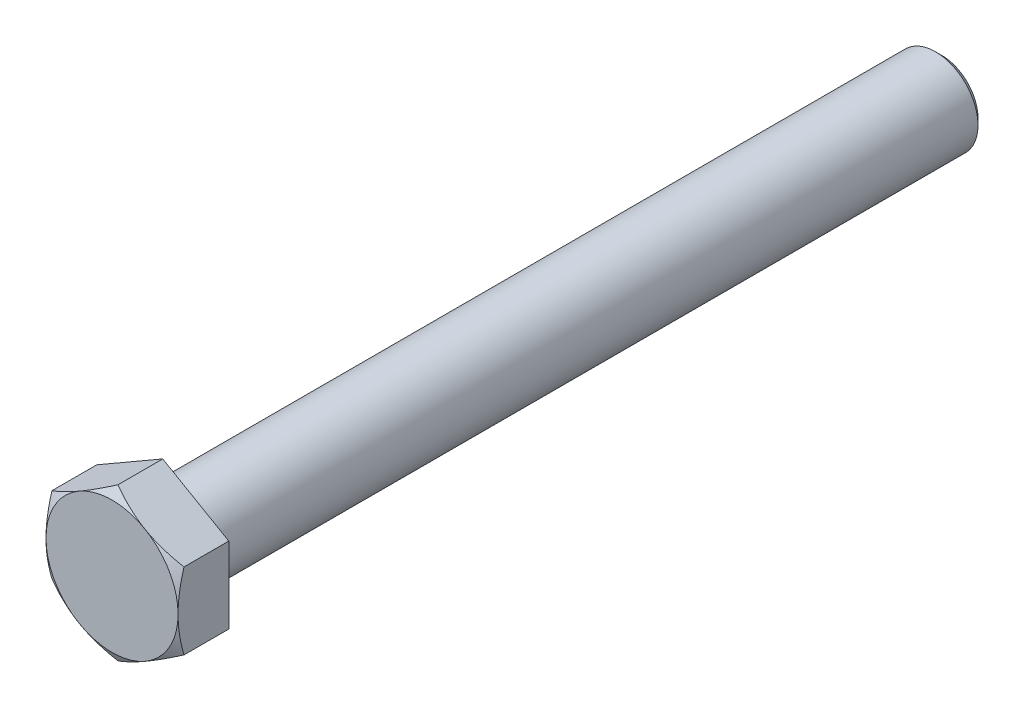
from build123d import *

# Parameters (mm, degrees)
BOSS_EXTRUDE1_DEPTH = 7.32


with BuildPart() as part:
    # Sketch1 → Boss-Extrude1 (new body)
    with BuildSketch(Plane.XY):
        Polygon((0, 10.779129526), (-9.335, 5.389564763), (-9.335, -5.389564763), (0, -10.779129526), (9.335, -5.389564763), (9.335, 5.389564763), align=None)
    extrude(amount=BOSS_EXTRUDE1_DEPTH)

    # Sketch2 → Revolve1 (revolve)
    with BuildSketch(Plane(origin=(0, 0, 0), x_dir=(0, 0, -1), z_dir=(1, 0, 0))):
        with BuildLine():
            Line((0, 0), (0, 6.6))
            ThreePointArc((0, 6.6), (0.175735931, 6.175735931), (0.6, 6))
            Line((0.6, 6), (109.1, 6))
            Line((109.1, 6), (110, 5.1))
            Line((110, 5.1), (110, 0))
            Line((110, 0), (0, 0))
        make_face()
    revolve(axis=Axis((0, 0, 0), (0, 0, -1)))

    # Sketch3 → Cut-Revolve1 (revolve, cut)
    with BuildSketch(Plane(origin=(0, 0, 0), x_dir=(0, 0, -1), z_dir=(1, 0, 0))):
        Polygon((-7.32, 10.779129526), (-6.48623143, 10.779129526), (-7.32, 9.335), align=None)
        Polygon((-0.15, 10.779129526), (-0.15, 8.78660254), (0, 8.7), (0, 10.779129526), align=None)
    revolve(axis=Axis((0, 0, 12.204941078), (0, 0, -1)), mode=Mode.SUBTRACT)


solid = part.part
